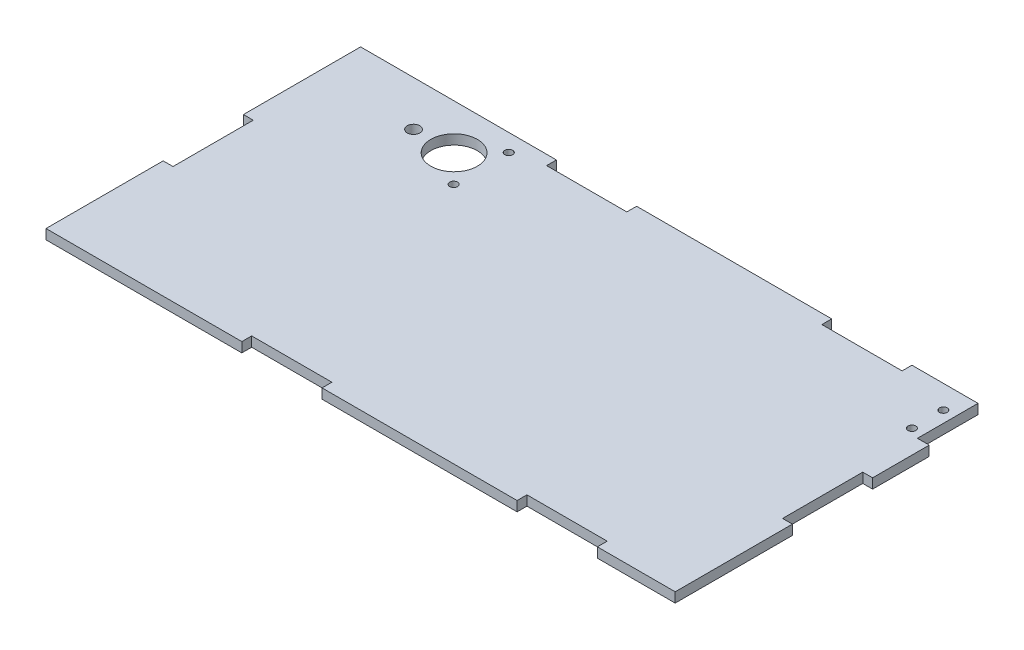
from build123d import *

# Parameters (mm, degrees)
SKETCH1_W           = 203.2
SKETCH1_H           = 101.6
SKETCH1_R           = 1.27
SKETCH1_R_2         = 7.5184
SKETCH1_R_3         = 2.032
BOSS_EXTRUDE1_DEPTH = 3.175
SKETCH2_W           = 25.908
SKETCH2_H           = 3.175
CUT_EXTRUDE1_DEPTH  = 3.175
SKETCH3_W           = 25.908
SKETCH3_H           = 3.175
CUT_EXTRUDE2_DEPTH  = 3.175
SKETCH5_W           = 25.908
SKETCH5_H           = 3.175
CUT_EXTRUDE3_DEPTH  = 3.175
SKETCH6_W           = 25.908
SKETCH6_H           = 3.175
CUT_EXTRUDE4_DEPTH  = 3.175
SKETCH7_W           = 3.81
SKETCH7_H           = 19.558
CUT_EXTRUDE5_DEPTH  = 3.175


with BuildPart() as part:
    # Sketch1 → Boss-Extrude1 (new body)
    with BuildSketch(Plane(origin=(0, 0, 0), x_dir=(1, 0, 0), z_dir=(0, 1, 0))):
        with Locations((26.275862069, -0.437931034)):
            Rectangle(SKETCH1_W, SKETCH1_H)
        with Locations((120.357219561, 32.709068966)):
            Circle(SKETCH1_R, mode=Mode.SUBTRACT)
        with Locations((120.357219561, 42.869068966)):
            Circle(SKETCH1_R, mode=Mode.SUBTRACT)
        with Locations((-30.609137931, 35.837068966)):
            Circle(SKETCH1_R_2, mode=Mode.SUBTRACT)
        with Locations((-43.709137931, 35.837068966)):
            Circle(SKETCH1_R_3, mode=Mode.SUBTRACT)
        with Locations((-21.859137931, 44.737068966)):
            Circle(SKETCH1_R, mode=Mode.SUBTRACT)
        with Locations((-21.859137931, 26.937068966)):
            Circle(SKETCH1_R, mode=Mode.SUBTRACT)
    extrude(amount=BOSS_EXTRUDE1_DEPTH)

    # Sketch2 → Cut-Extrude1 (cut)
    with BuildSketch(Plane(origin=(0, 0, -50.362068966), x_dir=(-1, 0, 0), z_dir=(0, 0, -1))):
        with Locations((-89.775862069, 1.5875)):
            Rectangle(SKETCH2_W, SKETCH2_H)
        with Locations((-0.875862069, 1.5875)):
            Rectangle(SKETCH2_W, SKETCH2_H)
    extrude(amount=-CUT_EXTRUDE1_DEPTH, mode=Mode.SUBTRACT)

    # Sketch3 → Cut-Extrude2 (cut)
    with BuildSketch(Plane.XY.offset(51.237931034)):
        with Locations((0.875862069, 1.5875)):
            Rectangle(SKETCH3_W, SKETCH3_H)
        with Locations((89.775862069, 1.5875)):
            Rectangle(SKETCH3_W, SKETCH3_H)
    extrude(amount=-CUT_EXTRUDE2_DEPTH, mode=Mode.SUBTRACT)

    # Sketch5 → Cut-Extrude3 (cut)
    with BuildSketch(Plane.ZY.offset(75.324137931)):
        with Locations((0.437931034, 1.5875)):
            Rectangle(SKETCH5_W, SKETCH5_H)
    extrude(amount=-CUT_EXTRUDE3_DEPTH, mode=Mode.SUBTRACT)

    # Sketch6 → Cut-Extrude4 (cut)
    with BuildSketch(Plane(origin=(127.875862069, 0, 0), x_dir=(0, 0, -1), z_dir=(1, 0, 0))):
        with Locations((-0.437931034, 1.5875)):
            Rectangle(SKETCH6_W, SKETCH6_H)
    extrude(amount=-CUT_EXTRUDE4_DEPTH, mode=Mode.SUBTRACT)

    # Sketch7 → Cut-Extrude5 (cut)
    with BuildSketch(Plane.XZ):
        with Locations((125.970862069, -40.583068966)):
            Rectangle(SKETCH7_W, SKETCH7_H)
    extrude(amount=-CUT_EXTRUDE5_DEPTH, mode=Mode.SUBTRACT)


solid = part.part
